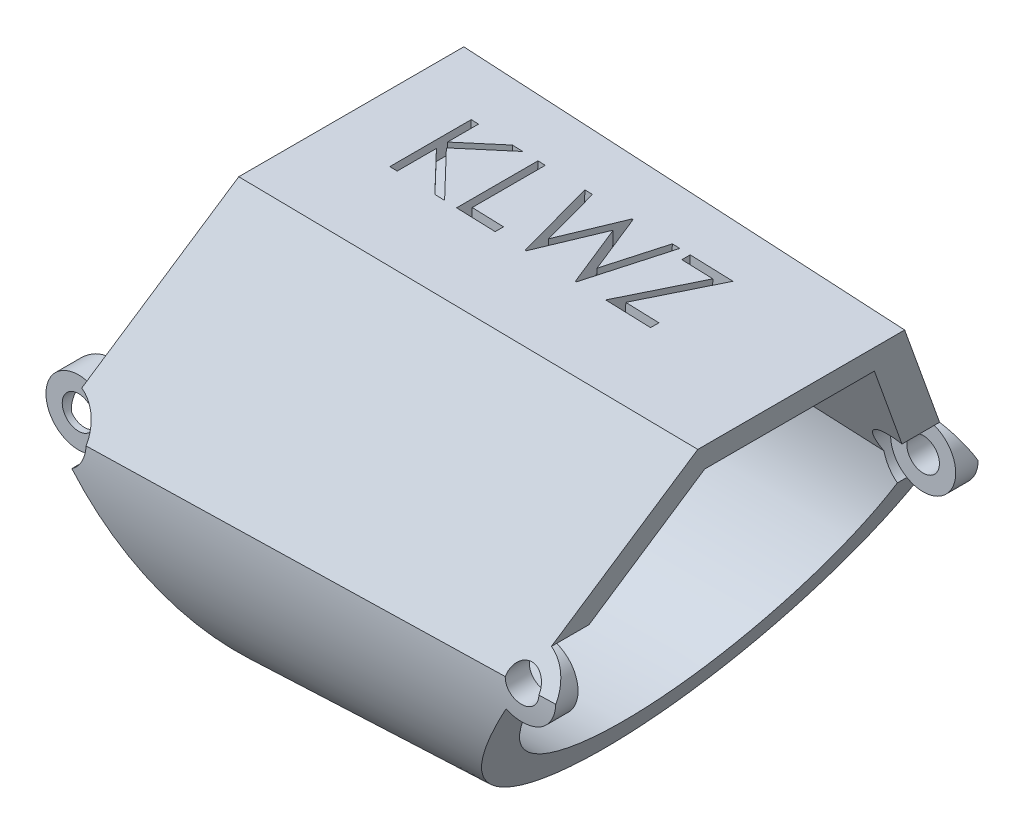
from build123d import *

# Parameters (mm, degrees)
BOSS_EXTRUDE1_DEPTH     = 20.32
BOSS_EXTRUDE1_TAPER     = 2
SHELL1_T                = -1.27
BOSS_EXTRUDE2_DEPTH     = 1.27
SKETCH2_R               = 0.635
CUT_EXTRUDE1_DEPTH      = 9.904502557
CUT_EXTRUDE1_DEPTH_BACK = 9.904502557
SKETCH5_R               = 1.27
CUT_EXTRUDE3_DEPTH      = 1.27
SKETCH6_R               = 1.27
CUT_EXTRUDE4_DEPTH      = 7.366
CUT_EXTRUDE4_DEPTH_BACK = 7.366
CUT_EXTRUDE2_DEPTH      = 0.762


with BuildPart() as part:
    # Sketch1 → Boss-Extrude1 (new body)
    with BuildSketch(Plane(origin=(0, 0, 0), x_dir=(0, 0, -1), z_dir=(1, 0, 0))):
        with BuildLine():
            Line((-4.445, 0), (-8.89, -7.69896584))
            ThreePointArc((-8.89, -7.69896584), (0, -17.111468296), (8.89, -7.69896584))
            Line((8.89, -7.69896584), (4.445, 0))
            Line((4.445, 0), (-4.445, 0))
        make_face()
    extrude(amount=BOSS_EXTRUDE1_DEPTH, taper=BOSS_EXTRUDE1_TAPER)

    # Shell1
    shell1_openings = [part.faces().sort_by_distance(p)[0] for p in [
        (20.32, -6.431402286, 0),
        (0, -6.202608534, 0),
    ]]
    offset(amount=SHELL1_T, openings=shell1_openings, kind=Kind.INTERSECTION)

    # Sketch4 → Boss-Extrude2 (add)
    with BuildSketch(Plane.ZY):
        with BuildLine():
            Line((-7.595601642, -8.96896584), (-7.874, -8.96896584))
            Line((-7.874, -8.96896584), (-7.874, -6.42896584))
            Line((-7.874, -6.42896584), (-6.689401596, -6.42896584))
            Line((-6.689401596, -6.42896584), (-7.63235574, -8.062210326))
            ThreePointArc((-7.63235574, -8.062210326), (-7.627465037, -8.516134733), (-7.595601642, -8.96896584))
        make_face()
        with BuildLine():
            Line((6.689401596, -6.42896584), (7.63235574, -8.062210326))
            ThreePointArc((7.63235574, -8.062210326), (7.627465037, -8.516134733), (7.595601642, -8.96896584))
            Line((7.595601642, -8.96896584), (7.874, -8.96896584))
            Line((7.874, -8.96896584), (7.874, -6.42896584))
            Line((7.874, -6.42896584), (6.689401596, -6.42896584))
        make_face()
    extrude(amount=BOSS_EXTRUDE2_DEPTH)

    # Sketch2 → Cut-Extrude1 (cut, two sides)
    with BuildSketch(Plane.XY) as cut_extrude1_sk:
        with Locations((0, -7.69896584)):
            Circle(SKETCH2_R)
        with Locations((17.710721046, -7.878525043)):
            Circle(SKETCH2_R)
        with BuildLine():
            Line((20.32, -0.709590036), (18.145086628, -6.685115414))
            ThreePointArc((18.145086628, -6.685115414), (18.861731936, -8.415250235), (17.075721046, -8.978377305))
            Line((17.075721046, -8.978377305), (12.63481581, -16.670250806))
            Line((12.63481581, -16.670250806), (20.32, -16.40187826))
            Line((20.32, -16.40187826), (20.32, -0.709590036))
        make_face()
        with BuildLine():
            Line((0.728442074, -8.739288936), (6.852393369, -17.485197771))
            Line((6.852393369, -17.485197771), (-2.129601865, -17.485197771))
            Line((-2.129601865, -17.485197771), (-2.129601865, 2.087266092))
            Line((-2.129601865, 2.087266092), (3.561897129, 2.087266092))
            Line((3.561897129, 2.087266092), (0.434365582, -6.505556211))
            ThreePointArc((0.434365582, -6.505556211), (-1.259134974, -7.864734104), (0.728442074, -8.739288936))
        make_face()
    extrude(amount=CUT_EXTRUDE1_DEPTH, mode=Mode.SUBTRACT)
    extrude(cut_extrude1_sk.sketch, amount=-CUT_EXTRUDE1_DEPTH_BACK, mode=Mode.SUBTRACT)

    # Sketch5 → Cut-Extrude3 (cut)
    with BuildSketch(Plane.XY.offset(7.874)):
        with Locations((0, -7.69896584)):
            Circle(SKETCH5_R)
    cut_extrude3 = extrude(amount=CUT_EXTRUDE3_DEPTH, mode=Mode.SUBTRACT)

    # Mirror1: Cut-Extrude3 across plane
    add(cut_extrude3.mirror(Plane.XY), mode=Mode.SUBTRACT)

    # Sketch6 → Cut-Extrude4 (cut, two sides)
    with BuildSketch(Plane.XY) as cut_extrude4_sk:
        with Locations((17.710721046, -7.878525043)):
            Circle(SKETCH6_R)
    extrude(amount=CUT_EXTRUDE4_DEPTH, mode=Mode.SUBTRACT)
    extrude(cut_extrude4_sk.sketch, amount=-CUT_EXTRUDE4_DEPTH_BACK, mode=Mode.SUBTRACT)

    # Sketch3 → Cut-Extrude2 (cut)
    with BuildSketch(Plane(origin=(0, 0, 0), x_dir=(0.999390827, -0.034899497, 0), z_dir=(0.034899497, 0.999390827, 0))):
        Polygon((5.287130105, 2.163145544), (5.572066002, 2.163145544), (5.572066002, 0.954076033), (6.895618687, 2.163145544), (7.302033951, 2.163145544), (5.741882709, 0.738466057), (7.424149336, -1.011854456), (7.044446812, -1.011854456), (5.572066002, 0.520312011), (5.572066002, -1.011854456), (5.287130105, -1.011854456), align=None)
        Polygon((7.89225831, 2.163145544), (8.177194208, 2.163145544), (8.177194208, -0.68621343), (9.398348054, -0.68621343), (9.398348054, -1.011854456), (7.89225831, -1.011854456), align=None)
        Polygon((9.723989079, 2.163145544), (10.018465241, 2.163145544), (10.639854464, -0.165314992), (11.563988078, 2.163145544), (11.605329224, 2.163145544), (12.512290361, -0.149414552), (13.136859672, 2.163145544), (13.428155746, 2.163145544), (12.572076018, -1.011854456), (12.53137089, -1.011854456), (11.576072413, 1.416460849), (10.609325618, -1.011854456), (10.56862049, -1.011854456), align=None)
        Polygon((13.835207028, 1.837504519), (13.835207028, 2.163145544), (15.504117284, 2.163145544), (14.172296371, -0.68621343), (15.463412156, -0.68621343), (15.463412156, -1.011854456), (13.713091643, -1.011854456), (15.044912557, 1.837504519), align=None)
    extrude(amount=-CUT_EXTRUDE2_DEPTH, mode=Mode.SUBTRACT)


solid = part.part
